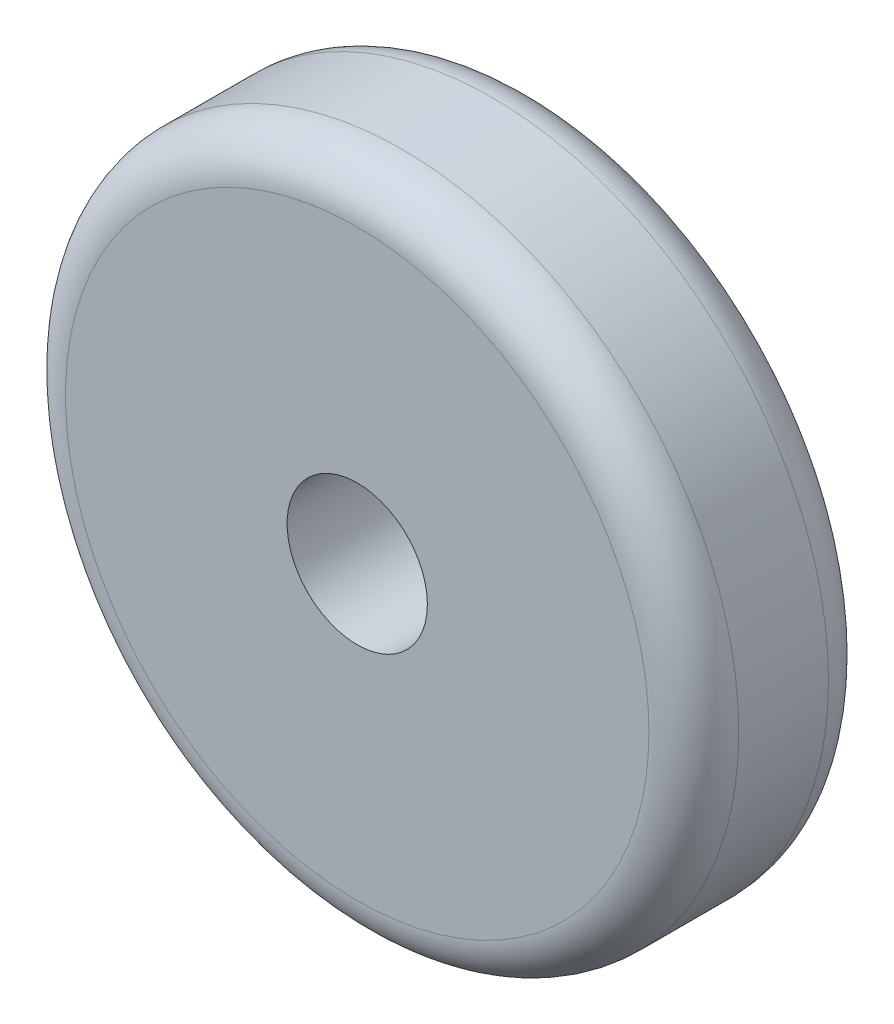
from build123d import *

# Parameters (mm, degrees)
SKETCH2_R           = 19.05
SKETCH2_R_2         = 3.96875
BOSS_EXTRUDE1_DEPTH = 10.16
FILLET1_R           = 2.54


with BuildPart() as part:
    # Sketch2 → Boss-Extrude1 (new body)
    with BuildSketch(Plane.XY):
        Circle(SKETCH2_R)
        Circle(SKETCH2_R_2, mode=Mode.SUBTRACT)
    extrude(amount=BOSS_EXTRUDE1_DEPTH)

    # Fillet1
    fillet1_edges = [part.edges().sort_by_distance(p)[0] for p in [
        (-19.05, 0, 0),
        (-19.05, 0, 10.16),
    ]]
    fillet(fillet1_edges, radius=FILLET1_R)


solid = part.part
